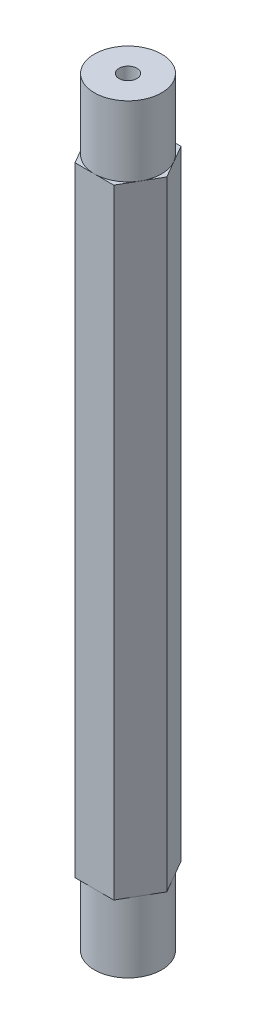
from build123d import *

# Parameters (mm, degrees)
SKETCH1_R           = 0.635
BOSS_EXTRUDE1_DEPTH = 21.9456
SKETCH2_R           = 2.38125
SKETCH2_R_2         = 0.635
BOSS_EXTRUDE2_DEPTH = 4.9784
SKETCH3_R           = 2.38125
SKETCH3_R_2         = 0.635
BOSS_EXTRUDE3_DEPTH = 4.9784


with BuildPart() as part:
    # Sketch1 → Boss-Extrude1 (new body, symmetric)
    with BuildSketch(Plane(origin=(0, 0, 0), x_dir=(1, 0, 0), z_dir=(0, 1, 0))):
        Polygon((1.374815329, -2.38125), (2.749630657, 0), (1.374815329, 2.38125), (-1.374815329, 2.38125), (-2.749630657, 0), (-1.374815329, -2.38125), align=None)
        Circle(SKETCH1_R, mode=Mode.SUBTRACT)
    extrude(amount=BOSS_EXTRUDE1_DEPTH, both=True)

    # Sketch2 → Boss-Extrude2 (add)
    with BuildSketch(Plane(origin=(0, 21.9456, 0), x_dir=(1, 0, 0), z_dir=(0, 1, 0))):
        Circle(SKETCH2_R)
        Circle(SKETCH2_R_2, mode=Mode.SUBTRACT)
    extrude(amount=BOSS_EXTRUDE2_DEPTH)

    # Sketch3 → Boss-Extrude3 (add)
    with BuildSketch(Plane.XZ.offset(21.9456)):
        Circle(SKETCH3_R)
        Circle(SKETCH3_R_2, mode=Mode.SUBTRACT)
    extrude(amount=BOSS_EXTRUDE3_DEPTH)


solid = part.part
